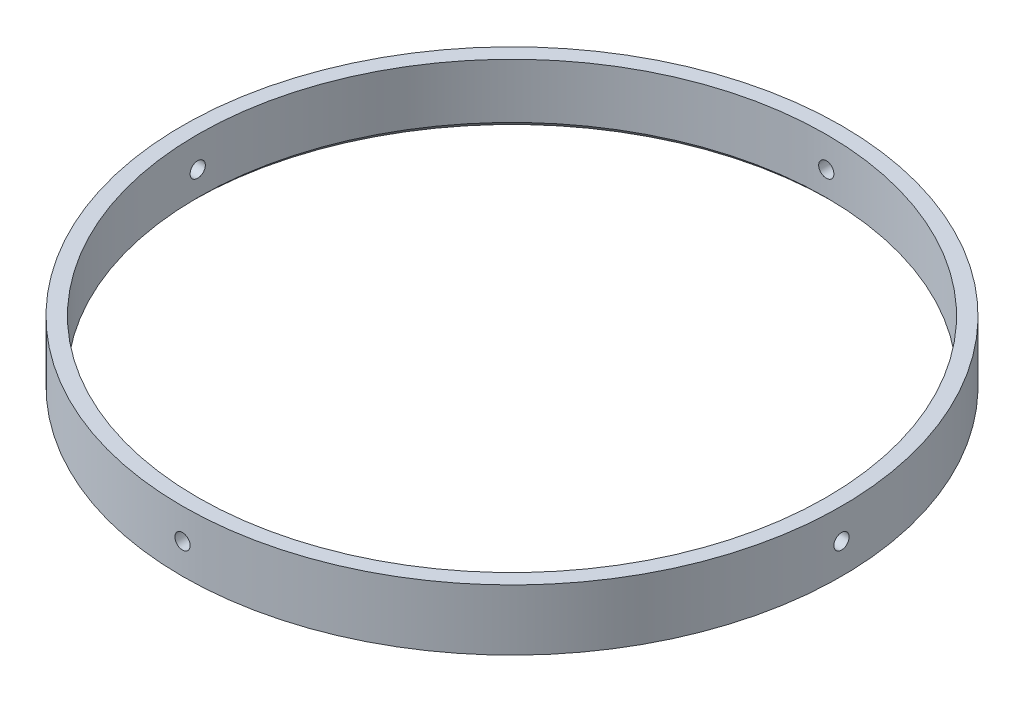
from build123d import *

# Parameters (mm, degrees)
SKETCH1_R           = 68.834
SKETCH1_R_2         = 65.659
BOSS_EXTRUDE1_DEPTH = 12.7
CUT_EXTRUDE1_START  = -68.834
SKETCH2_R           = 1.5875
CUT_EXTRUDE1_DEPTH  = 3.194194
CIRPATTERN1_COUNT   = 4
CHAMFER1_SIZE       = 1.27


with BuildPart() as part:
    # Sketch1 → Boss-Extrude1 (new body)
    with BuildSketch(Plane(origin=(0, 0, 0), x_dir=(1, 0, 0), z_dir=(0, 1, 0))):
        Circle(SKETCH1_R)
        Circle(SKETCH1_R_2, mode=Mode.SUBTRACT)
    extrude(amount=BOSS_EXTRUDE1_DEPTH)

    # Sketch2 → Cut-Extrude1 (cut)
    with BuildSketch(Plane.XY.offset(CUT_EXTRUDE1_START)):
        with Locations((0, 6.35)):
            Circle(SKETCH2_R)
    cut_extrude1 = extrude(amount=CUT_EXTRUDE1_DEPTH, mode=Mode.SUBTRACT)

    # CirPattern1: Cut-Extrude1 ×4 about axis
    cirpattern1_axis = Axis((0, 12.7, 0), (0, -1, 0))
    for i in range(1, CIRPATTERN1_COUNT):
        add(cut_extrude1.rotate(cirpattern1_axis, i * 360 / CIRPATTERN1_COUNT), mode=Mode.SUBTRACT)

    # Chamfer1
    chamfer1_edges = [part.edges().sort_by_distance(p)[0] for p in [
        (-65.659, 0, 0),
    ]]
    chamfer(chamfer1_edges, length=CHAMFER1_SIZE)


solid = part.part
